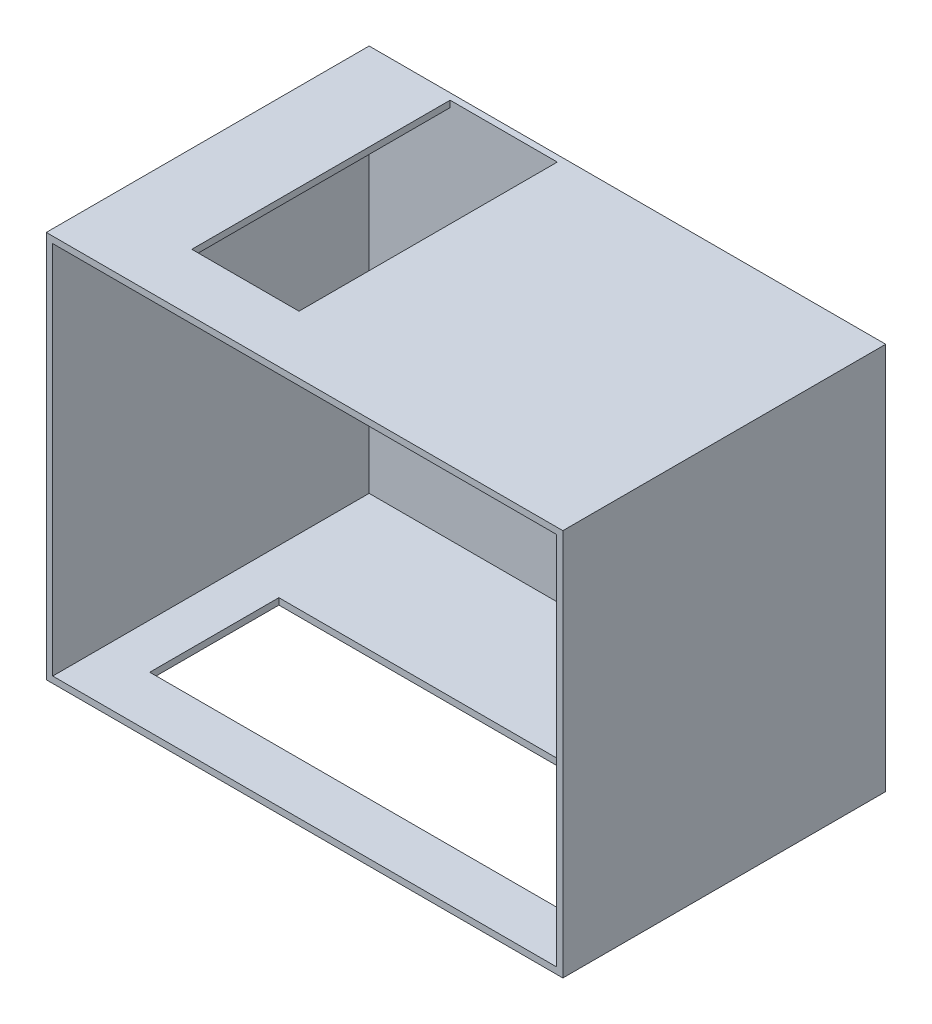
from build123d import *

# Parameters (mm, degrees)
ESQUISSE1_W             = 4000
ESQUISSE1_H             = 3000
BOSS_EXTRU_1_DEPTH      = 2500
COQUE1_T                = -50
ENL_V_MAT_EXTRU_1_REACH = 3002
ESQUISSE2_W             = 3200
ESQUISSE2_H             = 1000
ENL_V_MAT_EXTRU_2_REACH = 52
ESQUISSE3_W             = 830
ESQUISSE3_H             = 2000


with BuildPart() as part:
    # Esquisse1 → Boss.-Extru.1 (new body)
    with BuildSketch(Plane.XY):
        with Locations((1948.10540889, 1456.562305219)):
            Rectangle(ESQUISSE1_W, ESQUISSE1_H)
    extrude(amount=BOSS_EXTRU_1_DEPTH)

    # Coque1
    coque1_openings = [part.faces().sort_by_distance(p)[0] for p in [
        (1948.10540889, 1456.562305219, 2500),
    ]]
    offset(amount=COQUE1_T, openings=coque1_openings, kind=Kind.INTERSECTION)

    # Esquisse2 → Enlèv. mat.-Extru.1 (cut, up to next)
    with BuildSketch(Plane.XZ.offset(43.437694781), mode=Mode.PRIVATE) as enl_v_mat_extru_1_sk1:
        with Locations((1948.10540889, 1598.950328811)):
            Rectangle(ESQUISSE2_W, ESQUISSE2_H)
    enl_v_mat_extru_1_tool1 = extrude(enl_v_mat_extru_1_sk1.sketch, amount=-ENL_V_MAT_EXTRU_1_REACH, mode=Mode.PRIVATE) & part.part
    add(enl_v_mat_extru_1_tool1.solids().sort_by_distance((1948.105409, -43.437695, 1598.950329))[0], mode=Mode.SUBTRACT)

    # Esquisse3 → Enlèv. mat.-Extru.2 (cut, up to next)
    with BuildSketch(Plane.XZ.offset(-2906.562305219), mode=Mode.PRIVATE) as enl_v_mat_extru_2_sk1:
        with Locations((1039.930637484, 1050)):
            Rectangle(ESQUISSE3_W, ESQUISSE3_H)
    enl_v_mat_extru_2_tool1 = extrude(enl_v_mat_extru_2_sk1.sketch, amount=-ENL_V_MAT_EXTRU_2_REACH, mode=Mode.PRIVATE) & part.part
    add(enl_v_mat_extru_2_tool1.solids().sort_by_distance((1039.930637, 2906.562305, 1050))[0], mode=Mode.SUBTRACT)


solid = part.part
